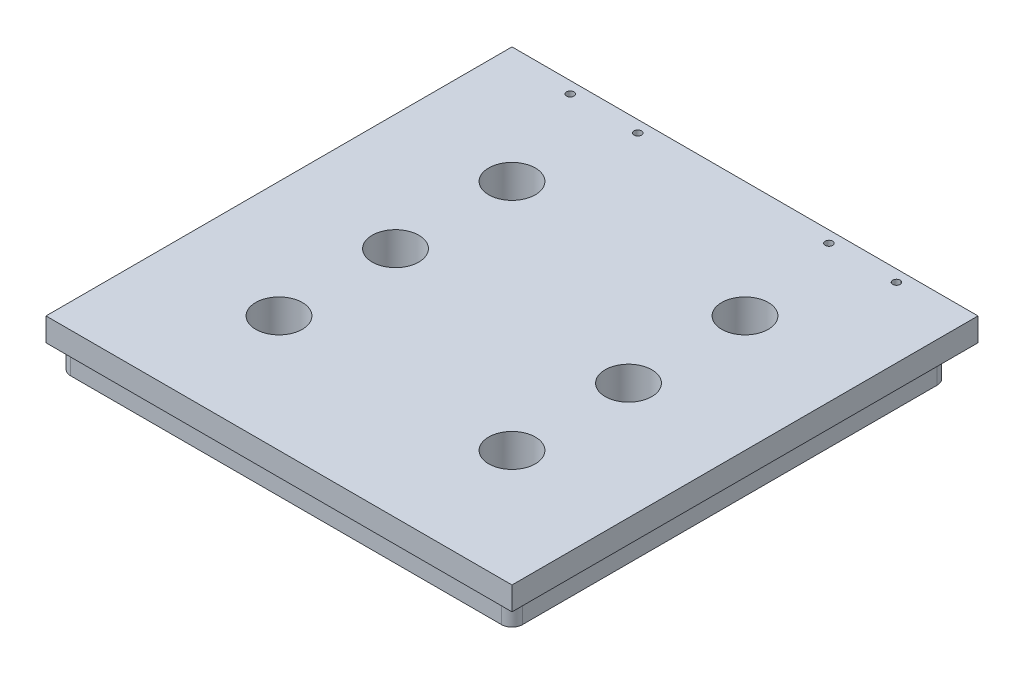
from build123d import *

# Parameters (mm, degrees)
CROQUIS1_W              = 200
CROQUIS1_H              = 200
SALIENTE_EXTRUIR1_DEPTH = 10
CROQUIS2_W              = 194
CROQUIS2_H              = 187
SALIENTE_EXTRUIR2_DEPTH = 10
REDONDEO2_R             = 4.5
CROQUIS3_R              = 10
CORTAR_EXTRUIR1_DEPTH   = 20
CROQUIS4_R              = 1.6
CORTAR_EXTRUIR2_DEPTH   = 10


with BuildPart() as part:
    # Croquis1 → Saliente-Extruir1 (new body)
    with BuildSketch(Plane(origin=(0, 0, 0), x_dir=(1, 0, 0), z_dir=(0, 1, 0))):
        Rectangle(CROQUIS1_W, CROQUIS1_H)
    extrude(amount=SALIENTE_EXTRUIR1_DEPTH)

    # Croquis2 → Saliente-Extruir2 (add)
    with BuildSketch(Plane.XZ):
        with Locations((0, 3.5)):
            Rectangle(CROQUIS2_W, CROQUIS2_H)
    extrude(amount=SALIENTE_EXTRUIR2_DEPTH)

    # Redondeo2
    redondeo2_edges = [part.edges().sort_by_distance(p)[0] for p in [
        (-97, -5, 97),
        (-97, -5, -90),
        (97, -5, -90),
        (97, -5, 97),
    ]]
    fillet(redondeo2_edges, radius=REDONDEO2_R)

    # Croquis3 → Cortar-Extruir1 (cut)
    with BuildSketch(Plane(origin=(0, 10, 0), x_dir=(1, 0, 0), z_dir=(0, 1, 0))):
        with Locations((-50, 50)):
            Circle(CROQUIS3_R)
        with Locations((-50, 0)):
            Circle(CROQUIS3_R)
        with Locations((-50, -50)):
            Circle(CROQUIS3_R)
    cortar_extruir1 = extrude(amount=-CORTAR_EXTRUIR1_DEPTH, mode=Mode.SUBTRACT)

    # Simetría1: Cortar-Extruir1 across plane
    add(cortar_extruir1.mirror(Plane(origin=(0, 0, 0), x_dir=(0, 0, 1), z_dir=(1, 0, 0))), mode=Mode.SUBTRACT)

    # Croquis4 → Cortar-Extruir2 (cut)
    with BuildSketch(Plane(origin=(0, 10, 0), x_dir=(1, 0, 0), z_dir=(0, 1, 0))):
        with Locations((-70, 95)):
            Circle(CROQUIS4_R)
        with Locations((-41, 95)):
            Circle(CROQUIS4_R)
    cortar_extruir2 = extrude(amount=-CORTAR_EXTRUIR2_DEPTH, mode=Mode.SUBTRACT)

    # Simetría2: Cortar-Extruir2 across plane
    add(cortar_extruir2.mirror(Plane(origin=(0, 0, 0), x_dir=(0, 0, 1), z_dir=(1, 0, 0))), mode=Mode.SUBTRACT)


solid = part.part
